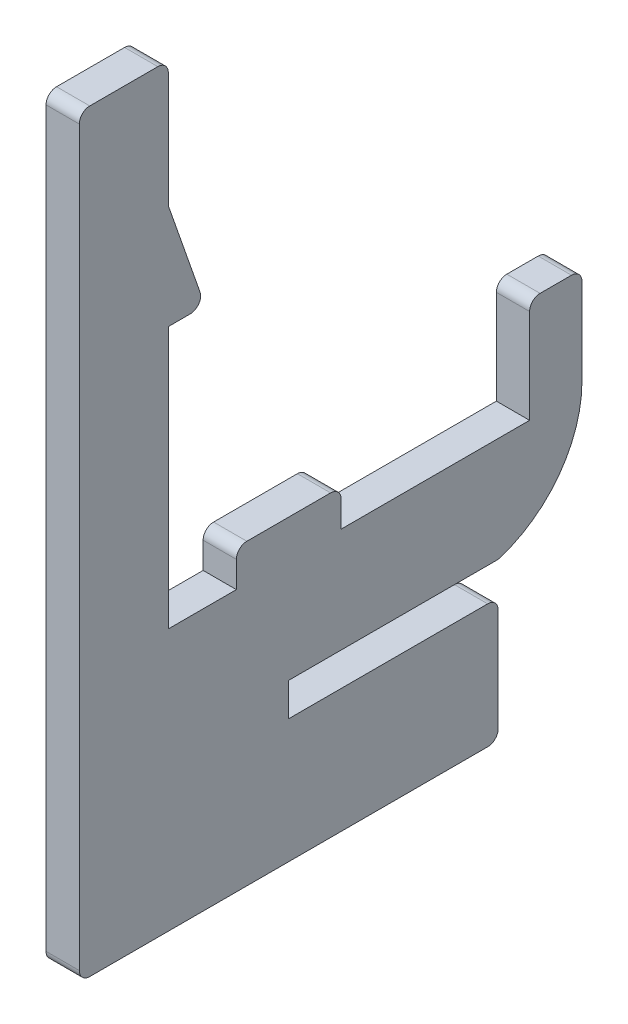
from build123d import *

# Parameters (mm, degrees)
BOSS_EXTRUDE1_DEPTH = 3.175
FILLET1_R           = 1


with BuildPart() as part:
    # Sketch1 → Boss-Extrude1 (new body)
    with BuildSketch(Plane(origin=(0, 0, 0), x_dir=(0, 0, -1), z_dir=(1, 0, 0))):
        with BuildLine():
            Line((6.5, 0), (0, 0))
            Line((0, 0), (0, 25))
            Line((0, 25), (3.5, 25))
            Line((3.5, 25), (0, 35))
            Line((0, 35), (0, 47))
            Line((0, 47), (-8.5, 47))
            Line((-8.5, 47), (-8.5, -25))
            Line((-8.5, -25), (31.5, -25))
            Line((31.5, -25), (31.5, -13.175))
            Line((31.5, -13.175), (11.5, -13.175))
            Line((11.5, -13.175), (11.5, -10))
            Line((11.5, -10), (31.5, -10))
            ThreePointArc((31.5, -10), (37.279601373, -5.967005826), (39.5, 0.721690905))
            Line((39.5, 0.721690905), (39.5, 10))
            Line((39.5, 10), (34.5, 10))
            Line((34.5, 10), (34.5, 0))
            Line((34.5, 0), (16.5, 0))
            Line((16.5, 0), (16.5, 3.5))
            Line((16.5, 3.5), (6.5, 3.5))
            Line((6.5, 3.5), (6.5, 0))
        make_face()
    extrude(amount=BOSS_EXTRUDE1_DEPTH)

    # Fillet1
    fillet1_edges = [part.edges().sort_by_distance(p)[0] for p in [
        (1.5875, -10, -31.5),
        (1.5875, -13.175, -31.5),
        (1.5875, -25, -31.5),
        (1.5875, -25, 8.5),
        (1.5875, 47, 8.5),
        (1.5875, 47, 0),
        (1.5875, 25, -3.5),
        (1.5875, 3.5, -6.5),
        (1.5875, 3.5, -16.5),
        (1.5875, 10, -34.5),
        (1.5875, 10, -39.5),
    ]]
    fillet(fillet1_edges, radius=FILLET1_R)


solid = part.part
